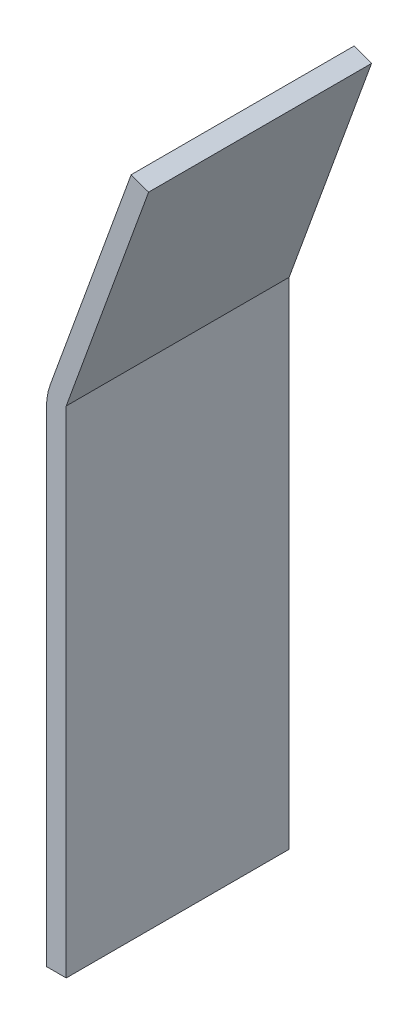
from build123d import *

# Parameters (mm, degrees)
BOSS_EXTRU_1_DEPTH      = 18
BOSS_EXTRU_1_DEPTH_BACK = 18
CONG_1_R                = 10


with BuildPart() as part:
    # Esquisse1 → Boss.-Extru.1 (new, two sides: drawn at the far end of the back side and taken through both)
    with BuildSketch(Plane.XY.offset(-BOSS_EXTRU_1_DEPTH_BACK)):
        Polygon((0, 0), (0, 80), (13.680805733, 117.587704831), (16.499883595, 116.561644401), (3.192533317, 80), (3.192533317, 0), align=None)
    extrude(amount=BOSS_EXTRU_1_DEPTH + BOSS_EXTRU_1_DEPTH_BACK)

    # Congé1
    cong_1_edges = [part.edges().sort_by_distance(p)[0] for p in [
        (0, 80, 0),
    ]]
    fillet(cong_1_edges, radius=CONG_1_R)


solid = part.part
